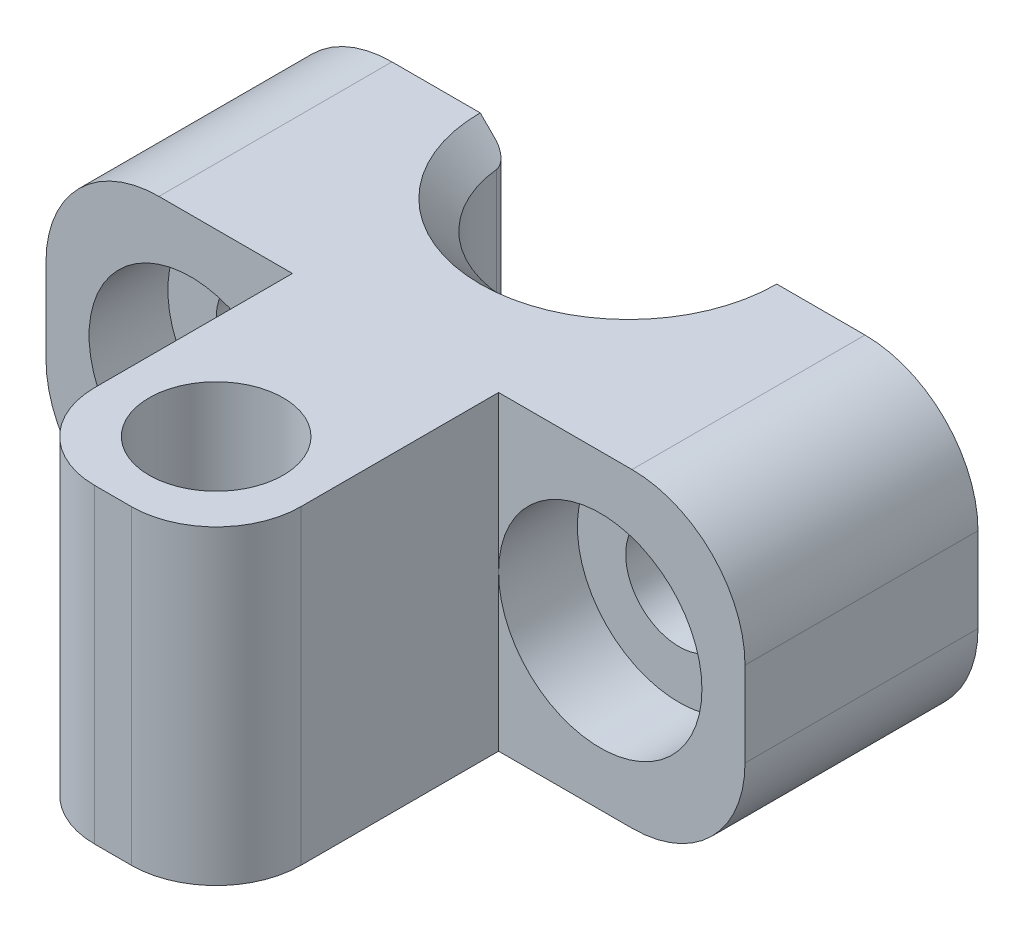
from build123d import *

# Parameters (mm, degrees)
CROQUIS1_W                                           = 24.75
CROQUIS1_H                                           = 11
SALIENTE_EXTRUIR1_DEPTH                              = 8.25
REFRENTADO_PARA_TORNILLO_CON_CABEZA_HEXA_D           = 3.78
REFRENTADO_PARA_TORNILLO_CON_CABEZA_HEXA_DEPTH       = 8.25
REFRENTADO_PARA_TORNILLO_CON_CABEZA_HEXA_CBORE_D     = 7.2
REFRENTADO_PARA_TORNILLO_CON_CABEZA_HEXA_CBORE_DEPTH = 2.79
DI_METRO_DE_TALADRO_8_5_8_5_1_D                      = 8.5
DI_METRO_DE_TALADRO_8_5_8_5_1_DEPTH                  = 11
CHAFL_N1_SIZE                                        = 1
REDONDEO1_R                                          = 0.5
REDONDEO2_R                                          = 4
CROQUIS6_W                                           = 7.3
CROQUIS6_H                                           = 11
SALIENTE_EXTRUIR3_DEPTH                              = 10
CROQUIS7_R                                           = 2.375
CORTAR_EXTRUIR1_DEPTH                                = 6.5000001
CORTAR_EXTRUIR1_DEPTH_BACK                           = 6.5000001
REDONDEO3_R                                          = 3


with BuildPart() as part:
    # Croquis1 → Saliente-Extruir1 (new body)
    with BuildSketch(Plane(origin=(0, 0, 0), x_dir=(-1, 0, 0), z_dir=(0, 0, -1))):
        Rectangle(CROQUIS1_W, CROQUIS1_H)
    extrude(amount=-SALIENTE_EXTRUIR1_DEPTH)

    # Refrentado para tornillo con cabeza hexagonal de M3.51
    with Locations(Plane.XY.offset(8.25)):
        with Locations((-7.25, 0), (7.25, 0)):
            CounterBoreHole(REFRENTADO_PARA_TORNILLO_CON_CABEZA_HEXA_D / 2, REFRENTADO_PARA_TORNILLO_CON_CABEZA_HEXA_CBORE_D / 2, REFRENTADO_PARA_TORNILLO_CON_CABEZA_HEXA_CBORE_DEPTH, depth=REFRENTADO_PARA_TORNILLO_CON_CABEZA_HEXA_DEPTH)

    # Diámetro de taladro Ø8.5 (8.5)1
    with Locations(Plane(origin=(0, 5.5, 0), x_dir=(1, 0, 0), z_dir=(0, 1, 0))):
        with Locations((0, 0)):
            Hole(DI_METRO_DE_TALADRO_8_5_8_5_1_D / 2, depth=DI_METRO_DE_TALADRO_8_5_8_5_1_DEPTH)

    # Chaflán1
    chafl_n1_edges = [part.edges().sort_by_distance(p)[0] for p in [
        (0, 5.5, 4.25),
        (0, -5.5, 4.25),
    ]]
    chamfer(chafl_n1_edges, length=CHAFL_N1_SIZE)

    # Redondeo1
    redondeo1_edges = [part.edges().sort_by_distance(p)[0] for p in [
        (4.25, 0, 0),
        (-4.25, 0, 0),
    ]]
    fillet(redondeo1_edges, radius=REDONDEO1_R)

    # Redondeo2
    redondeo2_edges = [part.edges().sort_by_distance(p)[0] for p in [
        (-12.375, 5.5, 4.125),
        (-12.375, -5.5, 4.125),
        (12.375, -5.5, 4.125),
        (12.375, 5.5, 4.125),
    ]]
    fillet(redondeo2_edges, radius=REDONDEO2_R)

    # Croquis6 → Saliente-Extruir3 (add)
    with BuildSketch(Plane.XY.offset(8.25)):
        Rectangle(CROQUIS6_W, CROQUIS6_H)
    extrude(amount=SALIENTE_EXTRUIR3_DEPTH)

    # Croquis7 → Cortar-Extruir1 (cut, two sides)
    with BuildSketch(Plane(origin=(0, 0, 0), x_dir=(1, 0, 0), z_dir=(0, 1, 0))) as cortar_extruir1_sk:
        with Locations((0, -14.6)):
            Circle(CROQUIS7_R)
    extrude(amount=CORTAR_EXTRUIR1_DEPTH, mode=Mode.SUBTRACT)
    extrude(cortar_extruir1_sk.sketch, amount=-CORTAR_EXTRUIR1_DEPTH_BACK, mode=Mode.SUBTRACT)

    # Redondeo3
    redondeo3_edges = [part.edges().sort_by_distance(p)[0] for p in [
        (3.65, 0, 18.25),
        (-3.65, 0, 18.25),
    ]]
    fillet(redondeo3_edges, radius=REDONDEO3_R)


solid = part.part
